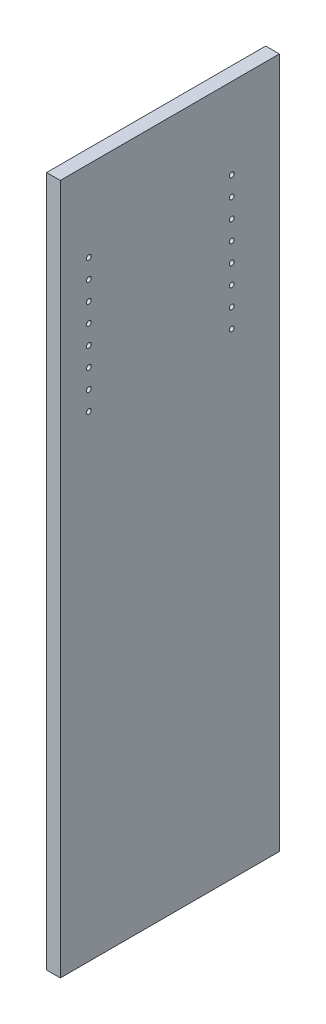
from build123d import *

# Parameters (mm, degrees)
SKETCH1_W           = 292.1
SKETCH1_H           = 920.75
BOSS_EXTRUDE1_DEPTH = 18.25625
SKETCH3_R           = 3.175
CUT_EXTRUDE1_DEPTH  = 9.525


with BuildPart() as part:
    # Sketch1 → Boss-Extrude1 (new body)
    with BuildSketch(Plane(origin=(0, 0, 0), x_dir=(0, 0, -1), z_dir=(1, 0, 0))):
        Rectangle(SKETCH1_W, SKETCH1_H)
    extrude(amount=BOSS_EXTRUDE1_DEPTH)

    # Sketch3 → Cut-Extrude1 (cut)
    with BuildSketch(Plane(origin=(18.25625, 0, 0), x_dir=(0, 0, -1), z_dir=(1, 0, 0))):
        with Locations((-107.95, 352.425)):
            Circle(SKETCH3_R)
        with Locations((-107.95, 327.025)):
            Circle(SKETCH3_R)
        with Locations((-107.95, 301.625)):
            Circle(SKETCH3_R)
        with Locations((-107.95, 276.225)):
            Circle(SKETCH3_R)
        with Locations((-107.95, 250.825)):
            Circle(SKETCH3_R)
        with Locations((-107.95, 225.425)):
            Circle(SKETCH3_R)
        with Locations((-107.95, 200.025)):
            Circle(SKETCH3_R)
        with Locations((-107.95, 174.625)):
            Circle(SKETCH3_R)
        with Locations((82.55, 174.625)):
            Circle(SKETCH3_R)
        with Locations((82.55, 200.025)):
            Circle(SKETCH3_R)
        with Locations((82.55, 225.425)):
            Circle(SKETCH3_R)
        with Locations((82.55, 250.825)):
            Circle(SKETCH3_R)
        with Locations((82.55, 276.225)):
            Circle(SKETCH3_R)
        with Locations((82.55, 301.625)):
            Circle(SKETCH3_R)
        with Locations((82.55, 327.025)):
            Circle(SKETCH3_R)
        with Locations((82.55, 352.425)):
            Circle(SKETCH3_R)
    extrude(amount=-CUT_EXTRUDE1_DEPTH, mode=Mode.SUBTRACT)


solid = part.part
